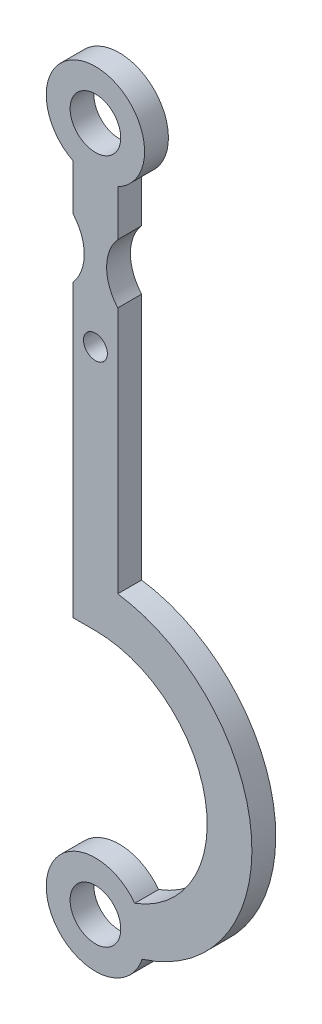
from build123d import *

# Parameters (mm, degrees)
SKETCH1_R           = 8.5
SKETCH1_R_2         = 4
BOSS_EXTRUDE1_DEPTH = 8


with BuildPart() as part:
    # Sketch1 → Boss-Extrude1 (new body)
    with BuildSketch(Plane.XY):
        with BuildLine():
            ThreePointArc((7.5, -14.696938457), (0, 16.5), (-7.5, -14.696938457))
            Line((-7.5, -14.696938457), (-7.5, -30.078432584))
            ThreePointArc((-7.5, -30.078432584), (-3.75, -40), (-7.5, -49.921567416))
            Line((-7.5, -49.921567416), (-7.5, -147.482509157))
            Line((-7.5, -147.482509157), (0, -147.482509157))
            ThreePointArc((0, -147.482509157), (36.911874913, -178.286162824), (13.210921757, -220.114579102))
            ThreePointArc((13.210921757, -220.114579102), (-16.280138823, -232.684600513), (15.685388352, -235.120409383))
            ThreePointArc((15.685388352, -235.120409383), (52.349526518, -180.803106174), (7.5, -133.020803734))
            Line((7.5, -133.020803734), (7.5, -49.921567416))
            ThreePointArc((7.5, -49.921567416), (3.75, -40), (7.5, -30.078432584))
            Line((7.5, -30.078432584), (7.5, -14.696938457))
        make_face()
        with Locations((0, -230)):
            Circle(SKETCH1_R, mode=Mode.SUBTRACT)
        with Locations((0, -65)):
            Circle(SKETCH1_R_2, mode=Mode.SUBTRACT)
        Circle(SKETCH1_R, mode=Mode.SUBTRACT)
    extrude(amount=BOSS_EXTRUDE1_DEPTH)


solid = part.part
